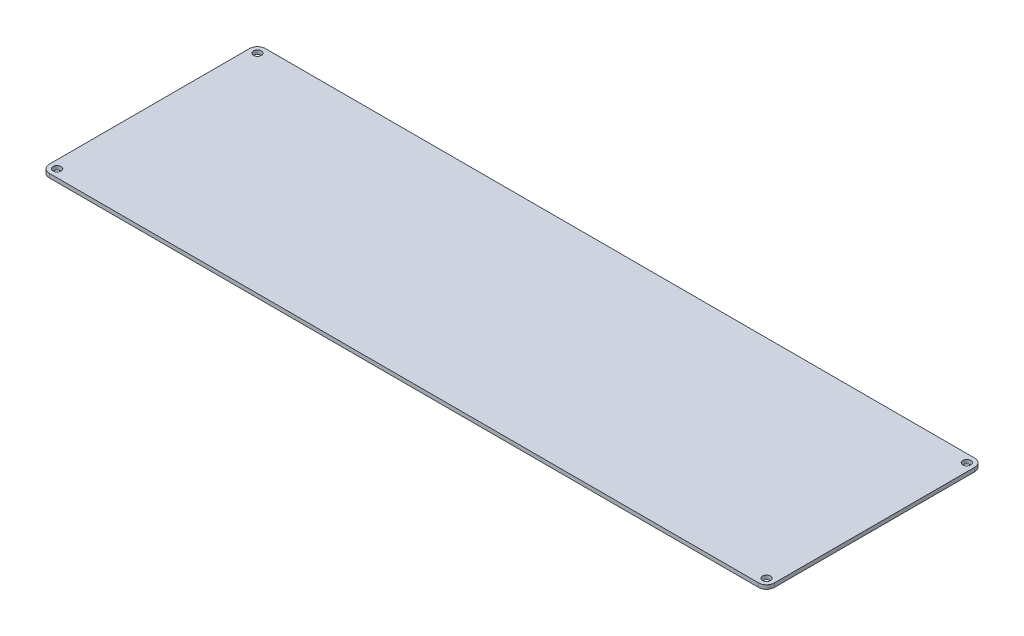
from build123d import *

# Parameters (mm, degrees)
SKETCH1_W           = 582.160000372
SKETCH1_H           = 173.482
SKETCH1_R           = 3.175
BOSS_EXTRUDE1_DEPTH = 3.175
FILLET1_R           = 6.35


with BuildPart() as part:
    # Sketch1 → Boss-Extrude1 (new body)
    with BuildSketch(Plane(origin=(0, 0, 0), x_dir=(1, 0, 0), z_dir=(0, 1, 0))):
        with Locations((42.871461676, 112.256050824)):
            Rectangle(SKETCH1_W, SKETCH1_H)
        with Locations((327.601461862, 192.647050824)):
            Circle(SKETCH1_R, mode=Mode.SUBTRACT)
        with Locations((327.601461862, 31.865050824)):
            Circle(SKETCH1_R, mode=Mode.SUBTRACT)
        with Locations((-241.85853851, 31.865050824)):
            Circle(SKETCH1_R, mode=Mode.SUBTRACT)
        with Locations((-241.85853851, 192.647050824)):
            Circle(SKETCH1_R, mode=Mode.SUBTRACT)
    extrude(amount=-BOSS_EXTRUDE1_DEPTH)

    # Fillet1
    fillet1_edges = [part.edges().sort_by_distance(p)[0] for p in [
        (333.951461862, -1.5875, -25.515050824),
        (-248.20853851, -1.5875, -25.515050824),
        (-248.20853851, -1.5875, -198.997050824),
        (333.951461862, -1.5875, -198.997050824),
    ]]
    fillet(fillet1_edges, radius=FILLET1_R)


solid = part.part
